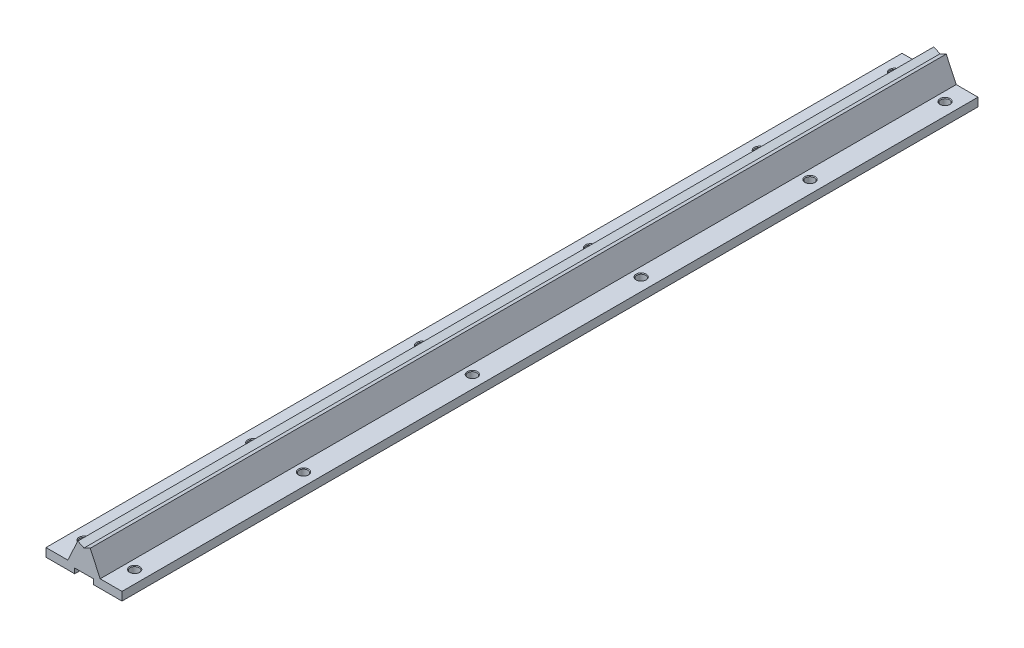
from build123d import *

# Parameters (mm, degrees)
BOSS_EXTRUDE1_DEPTH               = 507
TAP_DRILL_FOR_M5_TAP1_D           = 5.2
TAP_DRILL_FOR_M5_TAP1_DEPTH       = 46
TAP_DRILL_FOR_M5_TAP1_CSINK_D     = 6
TAP_DRILL_FOR_M5_TAP1_CSINK_ANGLE = 90
TAP_DRILL_FOR_M5_TAP1_TIP         = 1.562237609


with BuildPart() as part:
    # Sketch1 → Boss-Extrude1 (new body)
    with BuildSketch(Plane.XY):
        Polygon((5.5, 3), (-5.5, 3), (-5.5, 0), (-22.5, 0), (-22.5, 5), (-9.597702448, 5), (-3.67559519, 17.7), (0, 15.986041815), (3.67559519, 17.7), (9.597702448, 5), (22.5, 5), (22.5, 0), (5.5, 0), align=None)
    extrude(amount=BOSS_EXTRUDE1_DEPTH)

    # Tap Drill for M5 Tap1
    with Locations(Plane(origin=(-15, 5, 12), x_dir=(0, 0, 1), z_dir=(0, 1, 0))):
        with Locations((0, 0), (0, 30), (80, 0), (80, 30), (180, 0), (180, 30), (280, 0), (280, 30), (380, 0), (380, 30), (480, 0), (480, 30)):
            CounterSinkHole(TAP_DRILL_FOR_M5_TAP1_D / 2, TAP_DRILL_FOR_M5_TAP1_CSINK_D / 2, depth=TAP_DRILL_FOR_M5_TAP1_DEPTH, counter_sink_angle=TAP_DRILL_FOR_M5_TAP1_CSINK_ANGLE)
            with Locations((0, 0, -(TAP_DRILL_FOR_M5_TAP1_DEPTH + TAP_DRILL_FOR_M5_TAP1_TIP / 2))):  # 118° drill point
                Cone(0, TAP_DRILL_FOR_M5_TAP1_D / 2, TAP_DRILL_FOR_M5_TAP1_TIP, mode=Mode.SUBTRACT)


solid = part.part
